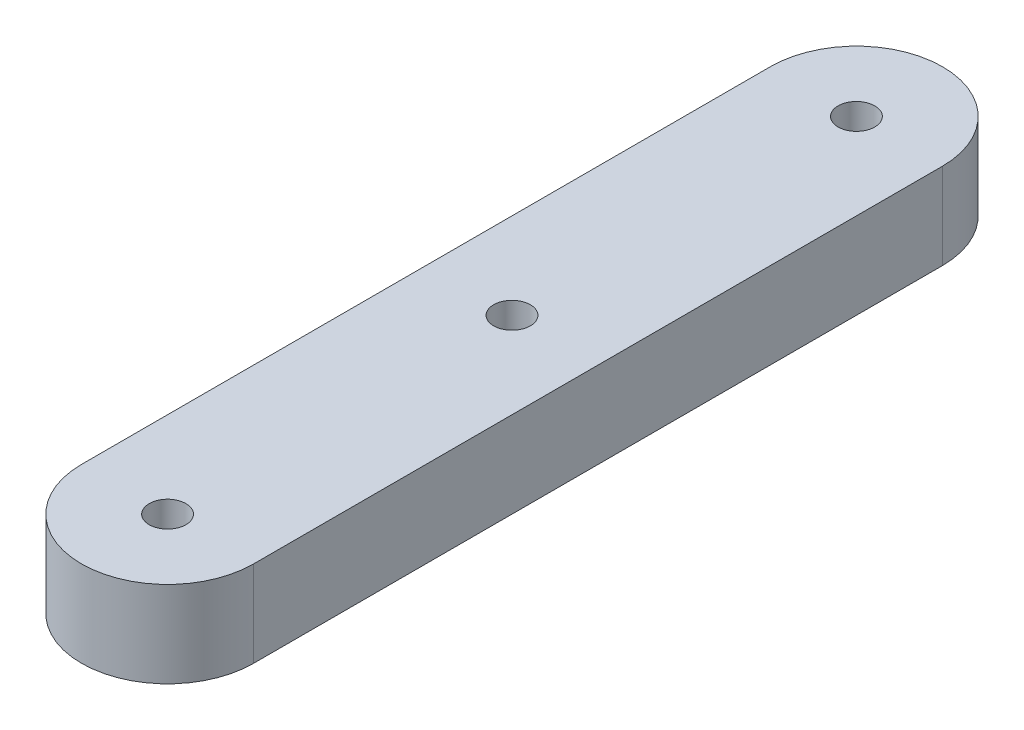
from build123d import *

# Parameters (mm, degrees)
BOSS_EXTRUDE1_DEPTH   = 6.35
F_6_32_TAPPED_HOLE1_D = 2.7051


with BuildPart() as part:
    # Sketch1 → Boss-Extrude1 (new body)
    with BuildSketch(Plane(origin=(0, 0, 0), x_dir=(1, 0, 0), z_dir=(0, 1, 0))):
        with BuildLine():
            Line((-6.35, -25.4), (-6.35, 25.4))
            ThreePointArc((-6.35, 25.4), (0, 31.75), (6.35, 25.4))
            Line((6.35, 25.4), (6.35, -25.4))
            ThreePointArc((6.35, -25.4), (0, -31.75), (-6.35, -25.4))
        make_face()
    extrude(amount=BOSS_EXTRUDE1_DEPTH)

    # #6-32 Tapped Hole1 (through all)
    with Locations(Plane(origin=(0, 6.35, 0), x_dir=(1, 0, 0), z_dir=(0, 1, 0))):
        with Locations((0, -25.4), (0, 25.4), (0, 0)):
            Hole(F_6_32_TAPPED_HOLE1_D / 2)


solid = part.part
